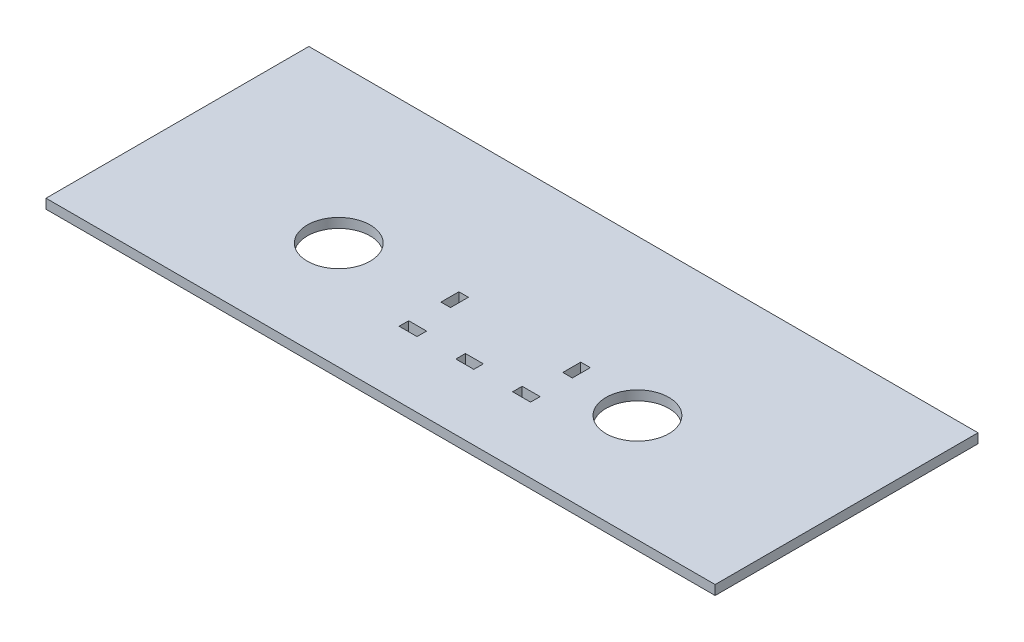
from build123d import *

# Parameters (mm, degrees)
SKETCH1_W           = 355.6
SKETCH1_H           = 139.7
BOSS_EXTRUDE1_DEPTH = 5.08
SKETCH2_R           = 16.7005
CUT_EXTRUDE1_DEPTH  = 6.08
SKETCH4_W           = 5.08
SKETCH4_H           = 9.525
SKETCH4_W_2         = 9.525
SKETCH4_H_2         = 5.08
CUT_EXTRUDE3_DEPTH  = 6.08


with BuildPart() as part:
    # Sketch1 → Boss-Extrude1 (new body)
    with BuildSketch(Plane(origin=(0, 0, 0), x_dir=(1, 0, 0), z_dir=(0, 1, 0))):
        Rectangle(SKETCH1_W, SKETCH1_H)
    extrude(amount=BOSS_EXTRUDE1_DEPTH)

    # Sketch2 → Cut-Extrude1 (cut, through all)
    with BuildSketch(Plane(origin=(0, 5.08, 0), x_dir=(1, 0, 0), z_dir=(0, 1, 0))):
        with Locations((-79.375, -12.7)):
            Circle(SKETCH2_R)
        with Locations((79.375, -12.7)):
            Circle(SKETCH2_R)
    extrude(amount=-CUT_EXTRUDE1_DEPTH, mode=Mode.SUBTRACT)

    # Sketch4 → Cut-Extrude3 (cut, through all)
    with BuildSketch(Plane(origin=(0, 5.08, 0), x_dir=(1, 0, 0), z_dir=(0, 1, 0))):
        with Locations((-22.5044, -7.9629)):
            Rectangle(SKETCH4_W, SKETCH4_H)
        with Locations((-20.2819, -32.4104)):
            Rectangle(SKETCH4_W_2, SKETCH4_H_2)
        with Locations((9.8806, -32.4104)):
            Rectangle(SKETCH4_W_2, SKETCH4_H_2)
        with Locations((40.0431, -32.4104)):
            Rectangle(SKETCH4_W_2, SKETCH4_H_2)
        with Locations((42.2656, -7.9629)):
            Rectangle(SKETCH4_W, SKETCH4_H)
    extrude(amount=-CUT_EXTRUDE3_DEPTH, mode=Mode.SUBTRACT)


solid = part.part
